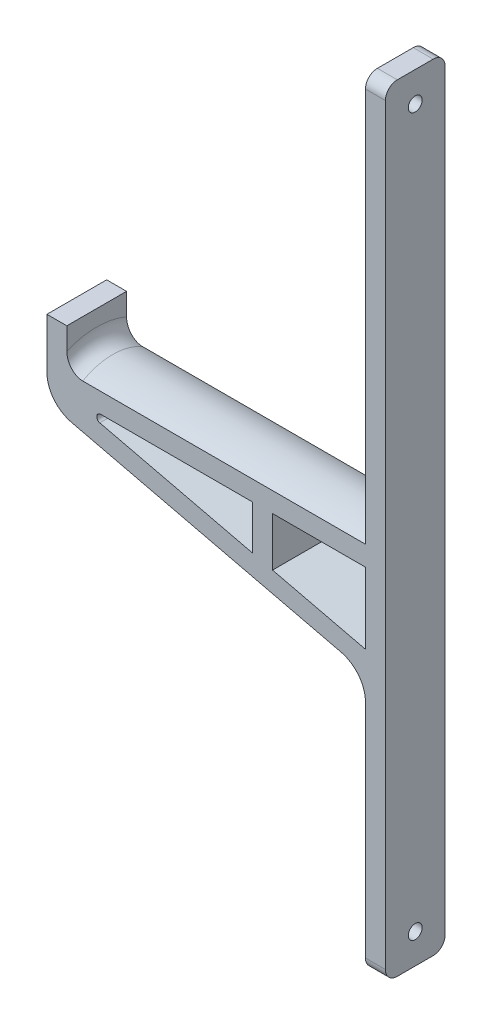
from build123d import *

# Parameters (mm, degrees)
RESSALTO_EXTRUS_O1_DEPTH = 7.5
ESBO_O2_R                = 1.7500000000000029
CORTE_EXTRUS_O1_DEPTH    = 10
FILETE1_R                = 1
CORTE_EXTRUS_O2_START    = -5
CORTE_EXTRUS_O2_DEPTH    = 75
FILETE2_R                = 3
FILETE3_R                = 8
FILETE4_R                = 4


with BuildPart() as part:
    # Esboço1 → Ressalto-extrusão1 (new, symmetric)
    with BuildSketch(Plane.XY):
        Polygon((-2.4999999999999947, -2.5000000000002314), (-77.5, -2.5000000000002305), (-77.5, 5.499999999999769), (-82.5, 5.499999999999769), (-82.5, -2.5000000000002314), (-82.5, -13.4491378645859), (-2.499999999999993, -32.50000000000023), (-2.499999999999994, -97.5000000000002), (2.500000000000006, -97.50000000000021), (2.4999999999999813, 97.4999999999998), (-2.4999999999999933, 97.4999999999998), align=None)
        Polygon((-2.4999999999999947, -9.500000000000231), (-25.833333333333332, -9.500000000000231), (-25.833333333333332, -21.80368179578865), (-2.499999999999992, -27.360183251951156), align=None, mode=Mode.SUBTRACT)
        Polygon((-77.5, -9.500000000000231), (-30.83333333333334, -20.613002912325253), (-30.833333333333336, -9.500000000000231), align=None, mode=Mode.SUBTRACT)
    extrude(amount=RESSALTO_EXTRUS_O1_DEPTH, both=True)

    # Esboço2 → Corte-extrusão1 (cut)
    with BuildSketch(Plane.ZY.offset(2.4999999999999947)):
        with Locations(Location((0, 90, 0), (0, 0, 270))):
            Circle(ESBO_O2_R)
        with Locations(Location((0, -90, 0), (0, 0, 270))):
            Circle(ESBO_O2_R)
    extrude(amount=-CORTE_EXTRUS_O1_DEPTH, mode=Mode.SUBTRACT)

    # Filete1
    filete1_edges = [part.edges().sort_by_distance(p)[0] for p in [
        (-77.5, -9.500000000000231, 0),
    ]]
    fillet(filete1_edges, radius=FILETE1_R)

    # Esboço3 → Corte-extrusão2 (cut)
    with BuildSketch(Plane.ZY.offset(82.5).offset(CORTE_EXTRUS_O2_START)):
        with BuildLine():
            Line((7.5, -4.5096189432336615), (7.5, -2.5000000000002363))
            Line((7.5, -2.5000000000002363), (0, -2.5000000000002363))
            ThreePointArc((-4.4e-16, -2.50000000000024), (3.8822856765378098, -3.0111126056642163), (7.500000000000002, -4.509618943233658))
        make_face()
        with BuildLine():
            ThreePointArc((-7.500000000000002, -4.509618943233658), (-3.8822856765378124, -3.0111126056642163), (-4.4e-16, -2.50000000000024))
            Line((0, -2.5000000000002363), (-7.5, -2.5000000000002363))
            Line((-7.5, -2.5000000000002363), (-7.5, -4.5096189432336615))
        make_face()
    extrude(amount=-CORTE_EXTRUS_O2_DEPTH, mode=Mode.SUBTRACT)

    # Filete2
    filete2_edges = [part.edges().sort_by_distance(p)[0] for p in [
        (-6.22e-15, 97.4999999999998, -7.5),
        (6.22e-15, -97.5000000000002, -7.5),
        (-6.22e-15, 97.4999999999998, 7.5),
        (6.22e-15, -97.5000000000002, 7.5),
    ]]
    fillet(filete2_edges, radius=FILETE2_R)

    # Filete3
    filete3_edges = [part.edges().sort_by_distance(p)[0] for p in [
        (-2.499999999999993, -32.50000000000023, 0),
        (-82.5, -13.4491378645859, 0),
    ]]
    fillet(filete3_edges, radius=FILETE3_R)

    # Filete4
    filete4_edges = [part.edges().sort_by_distance(p)[0] for p in [
        (-77.5, -2.5000000000002327, -1.44e-15),
    ]]
    fillet(filete4_edges, radius=FILETE4_R)


solid = part.part
